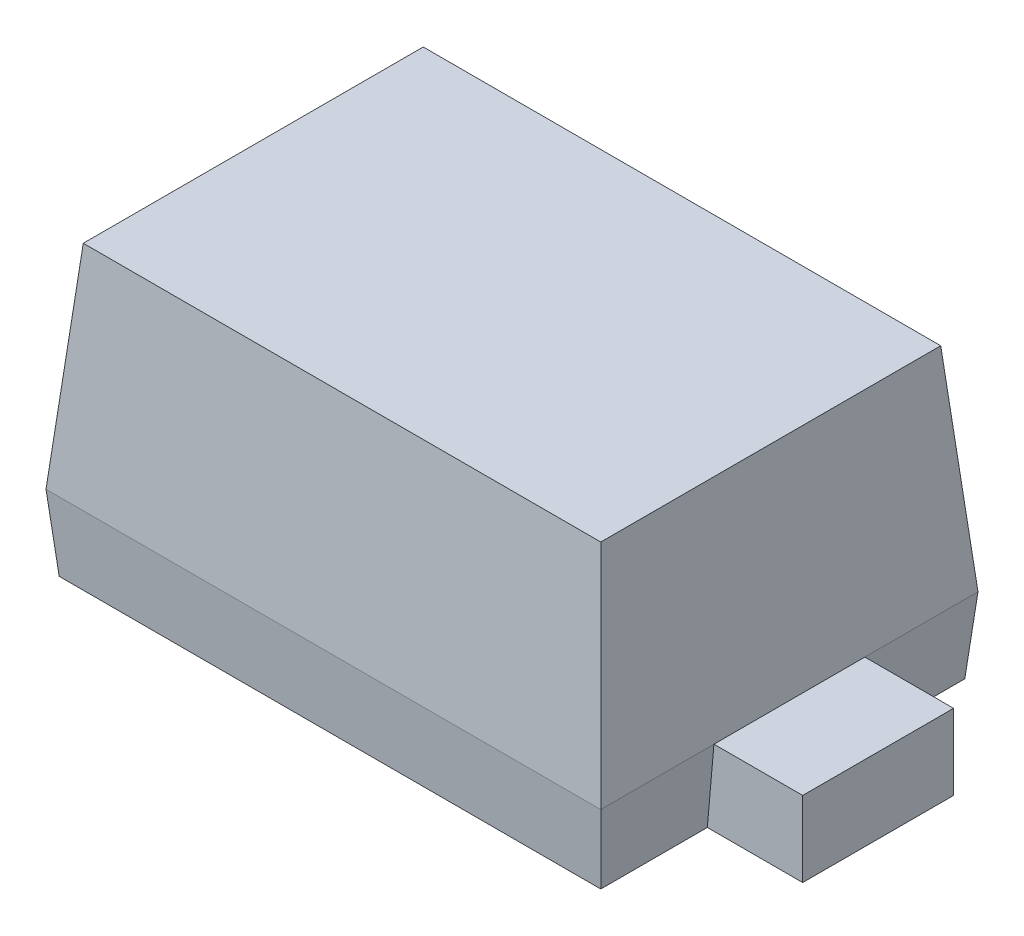
from build123d import *

# Parameters (mm, degrees)
SKETCH1_W                     = 1.25
SKETCH1_H                     = 0.85
BOSS_EXTRUDE1_DEPTH           = 0.48
BOSS_EXTRUDE1_TAPER           = 5
BOSS_EXTRUDE1_OTHER_WAY_DEPTH = 0.17
BOSS_EXTRUDE1_OTHER_WAY_TAPER = 5
BOSS_EXTRUDE2_DEPTH           = 0.17


with BuildPart() as part:
    # Sketch1 → Boss-Extrude1 (new body)
    with BuildSketch(Plane(origin=(0, 0, 0), x_dir=(1, 0, 0), z_dir=(0, 1, 0))):
        Rectangle(SKETCH1_W, SKETCH1_H)
    extrude(amount=BOSS_EXTRUDE1_DEPTH, taper=BOSS_EXTRUDE1_TAPER)

    # Sketch1 → Boss-Extrude1 other way (add)
    with BuildSketch(Plane(origin=(0, 0, 0), x_dir=(1, 0, 0), z_dir=(0, 1, 0))):
        Rectangle(SKETCH1_W, SKETCH1_H)
    extrude(amount=-BOSS_EXTRUDE1_OTHER_WAY_DEPTH, taper=BOSS_EXTRUDE1_OTHER_WAY_TAPER)

    # Sketch4 → Boss-Extrude2 (add)
    with BuildSketch(Plane.XZ.offset(0.17)):
        Polygon((-0.625, -0.17), (-0.583005442, -0.17), (-0.583005442, 0.17), (-0.625, 0.17), (-0.825, 0.17), (-0.825, -0.17), align=None)
        Polygon((0.625, -0.17), (0.825, -0.17), (0.825, 0.17), (0.625, 0.17), (0.583005442, 0.17), (0.583005442, -0.17), align=None)
    extrude(amount=-BOSS_EXTRUDE2_DEPTH)


solid = part.part
